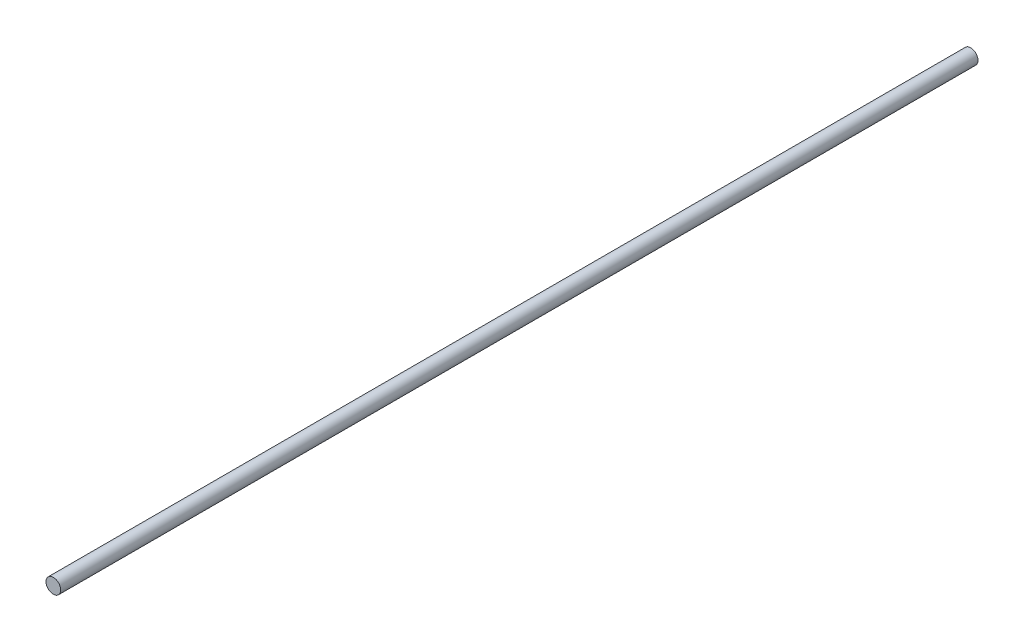
from build123d import *

# Parameters (mm, degrees)
SKETCH1_R             = 4
BOSS_EXTRUDE1_DEPTH   = 500
CROQUIS1_W            = 2
CROQUIS1_H            = 12
CORTAR_EXTRUIR1_DEPTH = 10


with BuildPart() as part:
    # Sketch1 → Boss-Extrude1 (new body)
    with BuildSketch(Plane.XY):
        Circle(SKETCH1_R)
    extrude(amount=-BOSS_EXTRUDE1_DEPTH)

    # Croquis1 → Cortar-Extruir1 (cut)
    with BuildSketch(Plane(origin=(0, 0, -500), x_dir=(-1, 0, 0), z_dir=(0, 0, -1))):
        with Locations((4, 0.404948668)):
            Rectangle(CROQUIS1_W, CROQUIS1_H)
    extrude(amount=-CORTAR_EXTRUIR1_DEPTH, mode=Mode.SUBTRACT)


solid = part.part
